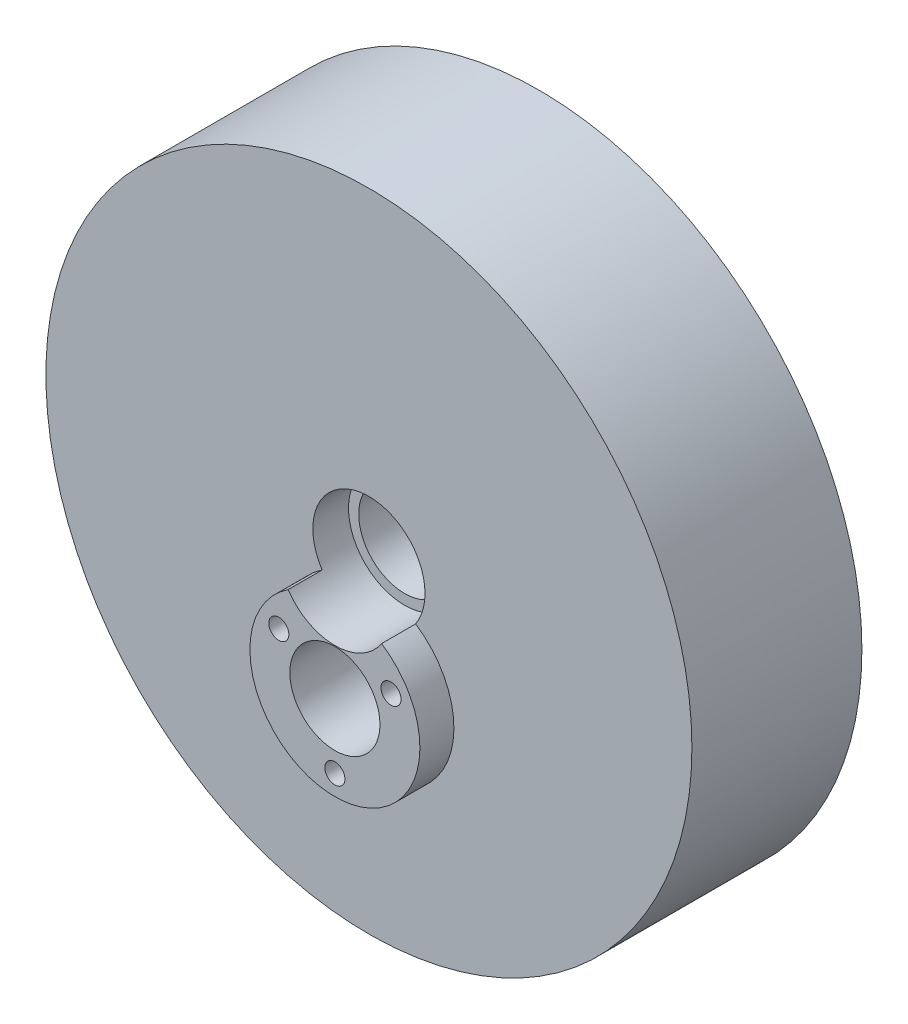
from build123d import *

# Parameters (mm, degrees)
SKETCH1_R           = 48.26
BOSS_EXTRUDE1_DEPTH = 25.4
SKETCH2_R           = 8.382
CUT_EXTRUDE1_DEPTH  = 5.334
SKETCH12_R          = 6.731
CUT_EXTRUDE5_DEPTH  = 73.823177629
SKETCH15_R          = 6.731
BOSS_EXTRUDE2_DEPTH = 5.08
SKETCH16_R          = 1.5
CUT_EXTRUDE9_DEPTH  = 75.746809965
SKETCH14_R          = 6.858
CUT_EXTRUDE8_DEPTH  = 73.823177629


with BuildPart() as part:
    # Sketch1 → Boss-Extrude1 (new body)
    with BuildSketch(Plane.XY):
        Circle(SKETCH1_R)
    extrude(amount=BOSS_EXTRUDE1_DEPTH)

    # Sketch2 → Cut-Extrude1 (cut)
    with BuildSketch(Plane.XY.offset(25.4)):
        Circle(SKETCH2_R)
    cut_extrude1 = extrude(amount=-CUT_EXTRUDE1_DEPTH, mode=Mode.SUBTRACT)

    # Sketch12 → Cut-Extrude5 (cut, through all)
    with BuildSketch(Plane(origin=(0, 0, 0), x_dir=(-1, 0, 0), z_dir=(0, 0, -1))):
        with Locations((0, -15.24)):
            Circle(SKETCH12_R)
    extrude(amount=-CUT_EXTRUDE5_DEPTH, mode=Mode.SUBTRACT)

    # Sketch15 → Boss-Extrude2 (add)
    with BuildSketch(Plane.XY.offset(25.4)):
        with BuildLine():
            ThreePointArc((6.984961194, -4.633383333), (0, -8.382), (-6.984961194, -4.633383333))
            ThreePointArc((-6.984961194, -4.633383333), (0, -27.94), (6.984961194, -4.633383333))
        make_face()
        with Locations(Location((0, -15.24, 0), (0, 0, 180))):
            Circle(SKETCH15_R, mode=Mode.SUBTRACT)
    extrude(amount=BOSS_EXTRUDE2_DEPTH)

    # Sketch16 → Cut-Extrude9 (cut, through all)
    with BuildSketch(Plane.XY.offset(30.48)):
        with Locations((8.379661807, -10.402)):
            Circle(SKETCH16_R)
        with Locations((0, -24.916)):
            Circle(SKETCH16_R)
        with Locations((-8.379661807, -10.402)):
            Circle(SKETCH16_R)
    extrude(amount=-CUT_EXTRUDE9_DEPTH, mode=Mode.SUBTRACT)

    # Mirror1: Cut-Extrude1 across plane
    add(cut_extrude1.mirror(Plane.XY.offset(12.7)), mode=Mode.SUBTRACT)

    # Sketch14 → Cut-Extrude8 (cut, through all)
    with BuildSketch(Plane.XY.offset(25.4)):
        Circle(SKETCH14_R)
    extrude(amount=-CUT_EXTRUDE8_DEPTH, mode=Mode.SUBTRACT)


solid = part.part
